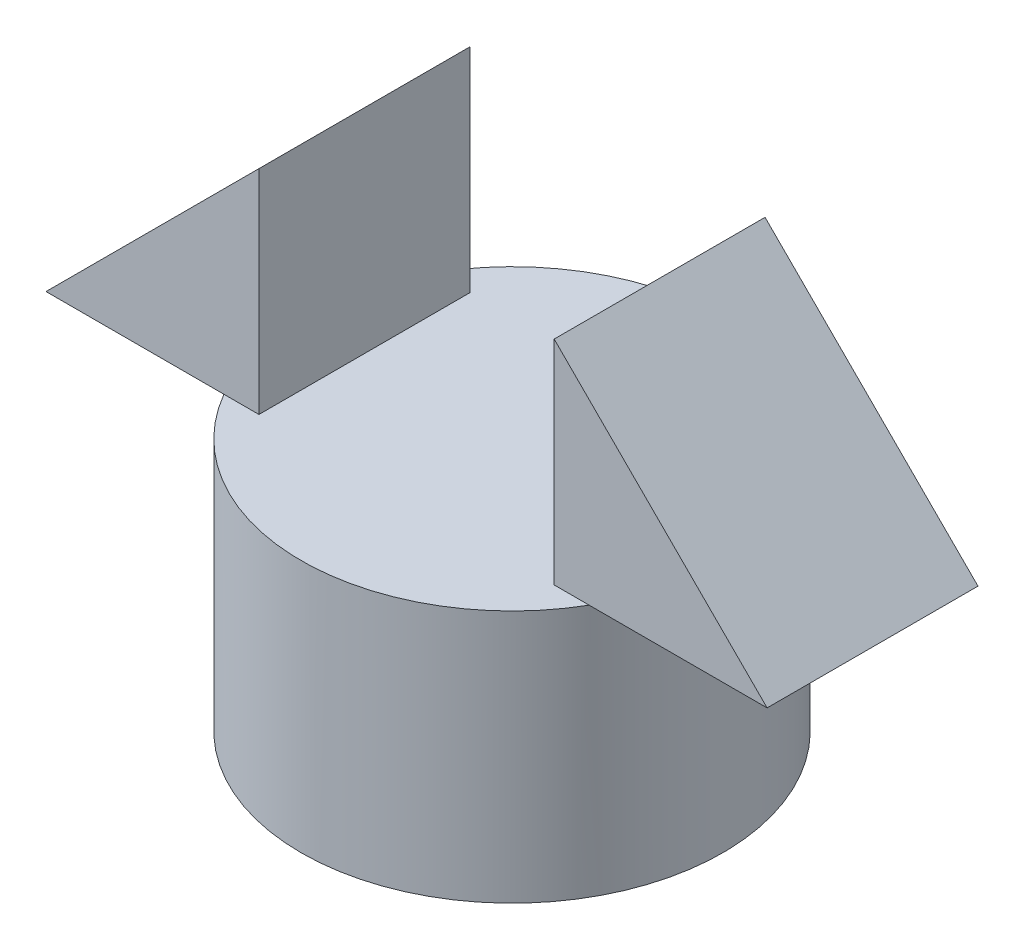
from build123d import *

# Parameters (mm, degrees)
SKETCH_1_R          = 25
EXTRUDE_1_DEPTH     = 30
EXTRUDE_2_DEPTH     = 12.5
CUT_EXTRUDE_1_DEPTH = 19


with BuildPart() as part:
    # 草图1 → 凸台-拉伸1 (new body)
    with BuildSketch(Plane(origin=(0, 0, 0), x_dir=(1, 0, 0), z_dir=(0, 1, 0))):
        Circle(SKETCH_1_R)
    extrude(amount=EXTRUDE_1_DEPTH)

    # 草图3 → 凸台-拉伸2 (add, symmetric)
    with BuildSketch(Plane.XY):
        Polygon((42.744510846, 30), (-42.744510846, 30), (0, 72.744510846), align=None)
    extrude(amount=EXTRUDE_2_DEPTH, both=True)

    # 草图4 → 切除-拉伸1 (cut, symmetric)
    with BuildSketch(Plane.XY):
        Polygon((17.500255974, 30), (-17.500255974, 30), (-17.500255974, 55.244254872), (0, 72.744510846), (17.500255974, 55.244254872), align=None)
    extrude(amount=CUT_EXTRUDE_1_DEPTH, both=True, mode=Mode.SUBTRACT)


solid = part.part
